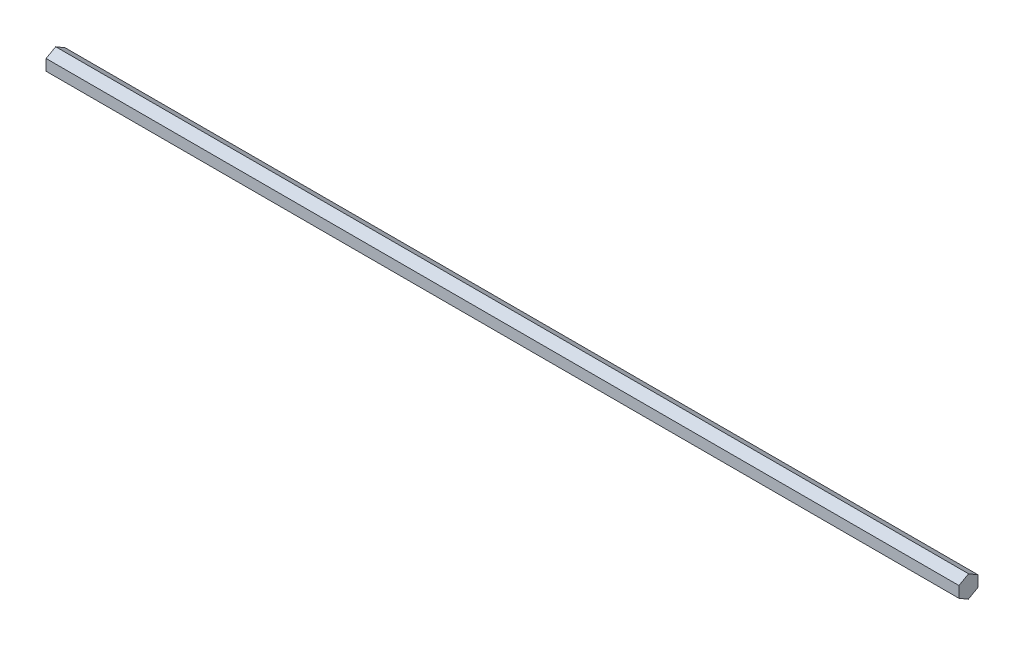
from build123d import *

# Parameters (mm, degrees)
BOSS_EXTRUDE1_DEPTH = 609.6


with BuildPart() as part:
    # Sketch1 → Boss-Extrude1 (new body)
    with BuildSketch(Plane(origin=(0, 0, 0), x_dir=(0, 0, -1), z_dir=(1, 0, 0))):
        Polygon((6.387063012, 3.601216379), (0.074786637, 7.331967014), (-6.312276375, 3.730750635), (-6.387063012, -3.601216379), (-0.074786637, -7.331967014), (6.312276375, -3.730750635), align=None)
    extrude(amount=BOSS_EXTRUDE1_DEPTH)


solid = part.part
